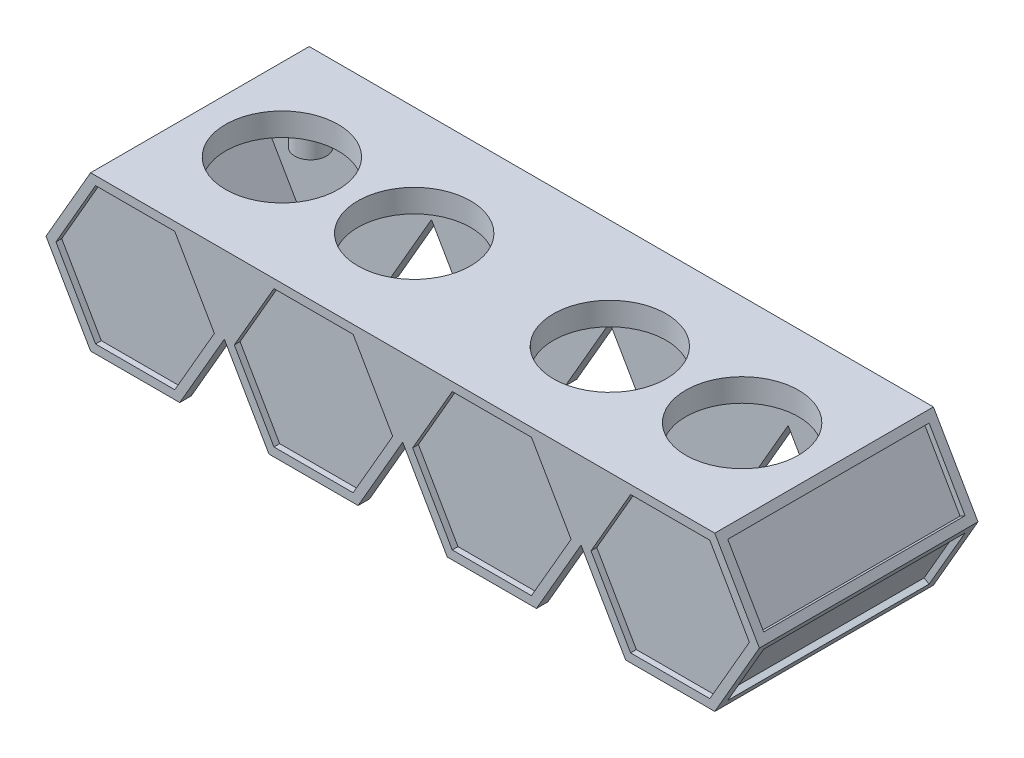
from build123d import *

# Parameters (mm, degrees)
BOSS_EXTRUDE1_DEPTH = 38
SHELL2_T            = -2
CUT_EXTRUDE2_DEPTH  = 1
CUT_EXTRUDE3_START  = -38
CUT_EXTRUDE3_DEPTH  = 1
SKETCH4_W           = 35
SKETCH4_H           = 12.5
CUT_EXTRUDE4_DEPTH  = 1
SKETCH5_W           = 35
SKETCH5_H           = 12.5
CUT_EXTRUDE5_DEPTH  = 1
SKETCH7_W           = 35
SKETCH7_H           = 12.5
CUT_EXTRUDE7_DEPTH  = 1
SKETCH8_W           = 35
SKETCH8_H           = 12.5
CUT_EXTRUDE8_DEPTH  = 1
SKETCH6_R           = 9.8
CUT_EXTRUDE6_DEPTH  = 10
SKETCH9_R           = 2.75
SKETCH9_R_2         = 1.5
BOSS_EXTRUDE2_DEPTH = 6
SKETCH11_W          = 2
SKETCH11_H          = 1.5
BOSS_EXTRUDE5_DEPTH = 18
SKETCH12_W          = 17.8
SKETCH12_H          = 2
CUT_EXTRUDE9_DEPTH  = 18
SKETCH14_R          = 10.8
SKETCH14_R_2        = 9.8
BOSS_EXTRUDE6_DEPTH = 2


with BuildPart() as part:
    # Sketch1 → Boss-Extrude1 (new body)
    with BuildSketch(Plane.XY):
        Polygon((-7.75, -13.423393759), (7.75, -13.423393759), (15.5, 0), (7.75, 13.423393759), (-7.75, 13.423393759), (-15.5, 0), align=None)
        Polygon((23.25, 13.423393759), (15.5, 0), (7.75, 13.423393759), align=None)
        Polygon((38.75, 13.423393759), (23.25, 13.423393759), (15.5, 0), (23.25, -13.423393759), (38.75, -13.423393759), (46.5, 0), align=None)
        Polygon((38.75, 13.423393759), (54.25, 13.423393759), (46.5, 0), align=None)
        Polygon((69.75, 13.423393759), (54.25, 13.423393759), (46.5, 0), (54.25, -13.423393759), (69.75, -13.423393759), (77.5, 0), align=None)
        Polygon((69.75, 13.423393759), (85.25, 13.423393759), (77.5, 0), align=None)
        Polygon((100.75, 13.423393759), (85.25, 13.423393759), (77.5, 0), (85.25, -13.423393759), (100.75, -13.423393759), (108.5, 0), align=None)
    extrude(amount=BOSS_EXTRUDE1_DEPTH)

    # Shell2
    shell2_openings = [part.faces().sort_by_distance(p)[0] for p in [
        (93, -13.423393759, 19),
        (81.375, -6.711696879, 19),
        (73.625, -6.711696879, 19),
        (62, -13.423393759, 19),
        (50.375, -6.711696879, 19),
        (42.625, -6.711696879, 19),
        (31, -13.423393759, 19),
        (19.375, -6.711696879, 19),
        (11.625, -6.711696879, 19),
        (0, -13.423393759, 19),
    ]]
    offset(amount=SHELL2_T, openings=shell2_openings, kind=Kind.INTERSECTION)

    # Sketch3 → Cut-Extrude2 (cut)
    with BuildSketch(Plane.XY.offset(38)):
        Polygon((13.767949192, 0), (6.883974596, 11.923393759), (-6.883974596, 11.923393759), (-13.767949192, 0), (-6.883974596, -11.923393759), (6.883974596, -11.923393759), align=None)
        Polygon((44.767949192, 0), (37.883974596, 11.923393759), (24.116025404, 11.923393759), (17.232050808, 0), (24.116025404, -11.923393759), (37.883974596, -11.923393759), align=None)
        Polygon((75.767949192, 0), (68.883974596, 11.923393759), (55.116025404, 11.923393759), (48.232050808, 0), (55.116025404, -11.923393759), (68.883974596, -11.923393759), align=None)
        Polygon((106.767949192, 0), (99.883974596, 11.923393759), (86.116025404, 11.923393759), (79.232050808, 0), (86.116025404, -11.923393759), (99.883974596, -11.923393759), align=None)
    extrude(amount=-CUT_EXTRUDE2_DEPTH, mode=Mode.SUBTRACT)

    # Sketch3_2 → Cut-Extrude3 (cut)
    with BuildSketch(Plane.XY.offset(38).offset(CUT_EXTRUDE3_START)):
        Polygon((13.767949192, 0), (6.883974596, 11.923393759), (-6.883974596, 11.923393759), (-13.767949192, 0), (-6.883974596, -11.923393759), (6.883974596, -11.923393759), align=None)
        Polygon((44.767949192, 0), (37.883974596, 11.923393759), (24.116025404, 11.923393759), (17.232050808, 0), (24.116025404, -11.923393759), (37.883974596, -11.923393759), align=None)
        Polygon((75.767949192, 0), (68.883974596, 11.923393759), (55.116025404, 11.923393759), (48.232050808, 0), (55.116025404, -11.923393759), (68.883974596, -11.923393759), align=None)
        Polygon((106.767949192, 0), (99.883974596, 11.923393759), (86.116025404, 11.923393759), (79.232050808, 0), (86.116025404, -11.923393759), (99.883974596, -11.923393759), align=None)
    extrude(amount=CUT_EXTRUDE3_DEPTH, mode=Mode.SUBTRACT)

    # Sketch4 → Cut-Extrude4 (cut)
    with BuildSketch(Plane(origin=(81.375, 46.981878155, 0), x_dir=(0, 0, -1), z_dir=(0.866025404, 0.5, 0))):
        with Locations((-19, -46.5)):
            Rectangle(SKETCH4_W, SKETCH4_H)
    extrude(amount=-CUT_EXTRUDE4_DEPTH, mode=Mode.SUBTRACT)

    # Sketch5 → Cut-Extrude5 (cut)
    with BuildSketch(Plane(origin=(-11.625, 6.711696879, 0), x_dir=(0, 0, 1), z_dir=(-0.866025404, 0.5, 0))):
        with Locations((19, 0)):
            Rectangle(SKETCH5_W, SKETCH5_H)
    extrude(amount=-CUT_EXTRUDE5_DEPTH, mode=Mode.SUBTRACT)

    # Sketch7 → Cut-Extrude7 (cut)
    with BuildSketch(Plane(origin=(-11.625, -6.711696879, 0), x_dir=(0, 0, 1), z_dir=(-0.866025404, -0.5, 0))):
        with Locations((19, 0)):
            Rectangle(SKETCH7_W, SKETCH7_H)
    extrude(amount=-CUT_EXTRUDE7_DEPTH, mode=Mode.SUBTRACT)

    # Sketch8 → Cut-Extrude8 (cut)
    with BuildSketch(Plane(origin=(81.375, -46.981878155, 0), x_dir=(0, 0, -1), z_dir=(0.866025404, -0.5, 0))):
        with Locations((-19, 46.5)):
            Rectangle(SKETCH8_W, SKETCH8_H)
    extrude(amount=-CUT_EXTRUDE8_DEPTH, mode=Mode.SUBTRACT)

    # Sketch6 → Cut-Extrude6 (cut)
    with BuildSketch(Plane(origin=(0, 13.423393759, 0), x_dir=(1, 0, 0), z_dir=(0, 1, 0))):
        with Locations((6.5, -19)):
            Circle(SKETCH6_R)
        with Locations((29.5, -19)):
            Circle(SKETCH6_R)
        with Locations((63.5, -19)):
            Circle(SKETCH6_R)
        with Locations((86.5, -19)):
            Circle(SKETCH6_R)
    extrude(amount=-CUT_EXTRUDE6_DEPTH, mode=Mode.SUBTRACT)

    # Sketch9 → Boss-Extrude2 (add)
    with BuildSketch(Plane.XZ.offset(-11.423393759)):
        with Locations((-0.5, 31)):
            Circle(SKETCH9_R)
        with Locations((-0.5, 31)):
            Circle(SKETCH9_R_2, mode=Mode.SUBTRACT)
        with Locations((-0.5, 7)):
            Circle(SKETCH9_R)
        with Locations((-0.5, 7)):
            Circle(SKETCH9_R_2, mode=Mode.SUBTRACT)
        with Locations((93.5, 31)):
            Circle(SKETCH9_R)
        with Locations((93.5, 31)):
            Circle(SKETCH9_R_2, mode=Mode.SUBTRACT)
        with Locations((93.5, 7)):
            Circle(SKETCH9_R)
        with Locations((93.5, 7)):
            Circle(SKETCH9_R_2, mode=Mode.SUBTRACT)
    extrude(amount=BOSS_EXTRUDE2_DEPTH)

    # Sketch11 → Boss-Extrude5 (add)
    with BuildSketch(Plane.XZ.offset(-11.423393759)):
        with Locations((52.1, 35.25)):
            Rectangle(SKETCH11_W, SKETCH11_H)
        with Locations((71.9, 35.25)):
            Rectangle(SKETCH11_W, SKETCH11_H)
    extrude(amount=BOSS_EXTRUDE5_DEPTH)

    # Sketch12 → Cut-Extrude9 (cut)
    with BuildSketch(Plane.XZ.offset(-11.423393759)):
        with Locations((62, 35.5)):
            Rectangle(SKETCH12_W, SKETCH12_H)
    extrude(amount=CUT_EXTRUDE9_DEPTH, mode=Mode.SUBTRACT)

    # Sketch14 → Boss-Extrude6 (add)
    with BuildSketch(Plane.XZ.offset(-11.423393759)):
        with Locations((6.5, 19)):
            Circle(SKETCH14_R)
        with Locations((6.5, 19)):
            Circle(SKETCH14_R_2, mode=Mode.SUBTRACT)
        with Locations((29.5, 19)):
            Circle(SKETCH14_R)
        with Locations((29.5, 19)):
            Circle(SKETCH14_R_2, mode=Mode.SUBTRACT)
        with Locations((63.5, 19)):
            Circle(SKETCH14_R)
        with Locations((63.5, 19)):
            Circle(SKETCH14_R_2, mode=Mode.SUBTRACT)
        with Locations((86.5, 19)):
            Circle(SKETCH14_R)
        with Locations((86.5, 19)):
            Circle(SKETCH14_R_2, mode=Mode.SUBTRACT)
    extrude(amount=BOSS_EXTRUDE6_DEPTH)


solid = part.part
